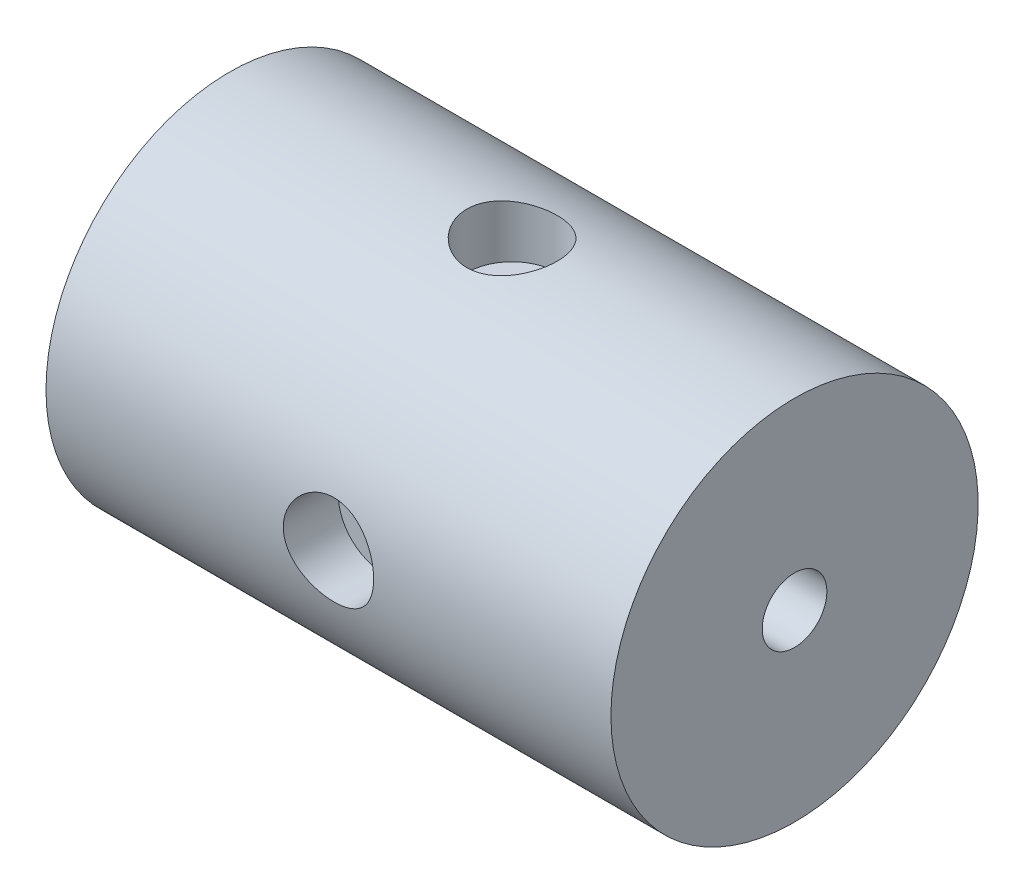
from build123d import *

# Parameters (mm, degrees)
G1_4_GEWINDEBOHRUNG1_D          = 11.445
G1_4_GEWINDEBOHRUNG1_DEPTH      = 100
SKIZZE6_R                       = 8
SCHNITT_LINEAR_AUSTRAGEN1_DEPTH = 9.75
SKIZZE7_R                       = 5
SCHNITT_LINEAR_AUSTRAGEN2_DEPTH = 30
KREISMUSTER1_COUNT              = 3
KREISMUSTER1_ANGLE              = 180


with BuildPart() as part:
    # Skizze1 → Rotation1 (revolve)
    with BuildSketch(Plane.XY):
        Polygon((0, 17.25), (0, 32.5), (100, 32.5), (100, 1.5), (85, 1.5), (76.625576451, 17.25), align=None)
    revolve(axis=Axis((0, 0, 0), (1, 0, 0)))

    # G1/4 Gewindebohrung1
    with Locations(Plane(origin=(100, 0, 0), x_dir=(0, 0, 1), z_dir=(1, 0, 0))):
        with Locations((0, 0)):
            Hole(G1_4_GEWINDEBOHRUNG1_D / 2, depth=G1_4_GEWINDEBOHRUNG1_DEPTH)

    # Skizze6 → Schnitt-Linear austragen1 (cut)
    with BuildSketch(Plane.XY.offset(32.5)):
        with Locations((50, 0)):
            Circle(SKIZZE6_R)
    schnitt_linear_austragen1 = extrude(amount=-SCHNITT_LINEAR_AUSTRAGEN1_DEPTH, mode=Mode.SUBTRACT)

    # Skizze7 → Schnitt-Linear austragen2 (cut)
    with BuildSketch(Plane.XY.offset(32.5)):
        with Locations((50, 0)):
            Circle(SKIZZE7_R)
    schnitt_linear_austragen2 = extrude(amount=-SCHNITT_LINEAR_AUSTRAGEN2_DEPTH, mode=Mode.SUBTRACT)

    # Kreismuster1: Schnitt-Linear austragen1, Schnitt-Linear austragen2 ×3 about axis
    kreismuster1_axis = Axis((0, 0, 0), (-1, 0, 0))
    for i in range(1, KREISMUSTER1_COUNT):
        add(schnitt_linear_austragen1.rotate(kreismuster1_axis, i * KREISMUSTER1_ANGLE / (KREISMUSTER1_COUNT - 1)), mode=Mode.SUBTRACT)
        add(schnitt_linear_austragen2.rotate(kreismuster1_axis, i * KREISMUSTER1_ANGLE / (KREISMUSTER1_COUNT - 1)), mode=Mode.SUBTRACT)


solid = part.part
